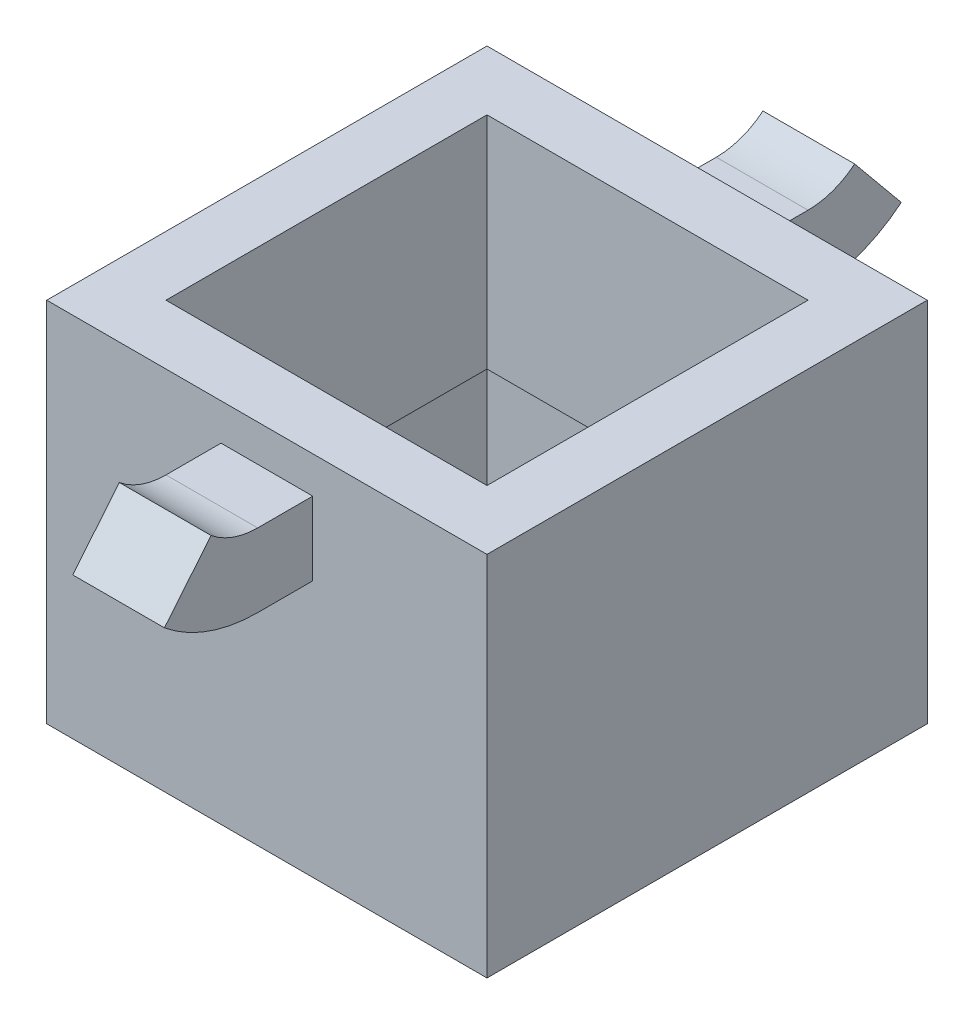
from build123d import *

# Parameters (mm, degrees)
SKETCH1_W           = 24
SKETCH1_H           = 24
BOSS_EXTRUDE1_DEPTH = 20
SKETCH5_W           = 5
SKETCH5_H           = 4
SKETCH3_W           = 20
SKETCH3_H           = 20
CUT_EXTRUDE5_DEPTH  = 6
SKETCH14_W          = 20
SKETCH14_H          = 20
CUT_EXTRUDE6_DEPTH  = 2
CUT_EXTRUDE7_REACH  = 14
SKETCH15_W          = 17.5
SKETCH15_H          = 17.5


with BuildPart() as part:
    # Sketch1 → Boss-Extrude1 (new body)
    with BuildSketch(Plane(origin=(0, 0, 0), x_dir=(1, 0, 0), z_dir=(0, 1, 0))):
        Rectangle(SKETCH1_W, SKETCH1_H)
    extrude(amount=BOSS_EXTRUDE1_DEPTH)

    # Sweep1: sweep along a path in Sketch6
    with BuildLine(Plane(origin=(0, 0, 0), x_dir=(0, 0, -1), z_dir=(1, 0, 0))) as sweep1_path:
        Line((12, 16), (15, 16))
        ThreePointArc((15, 16), (17.025627927, 16.352272006), (18.813398517, 17.367722833))
    # Sketch5 → Sweep1 (sweep)
    with BuildSketch(Plane(origin=(0, 0, -12), x_dir=(-1, 0, 0), z_dir=(0, 0, -1))):
        with Locations((0, 16)):
            Rectangle(SKETCH5_W, SKETCH5_H)
    sweep1 = sweep(path=sweep1_path.line)

    # Mirror1: Sweep1 across plane
    add(sweep1.mirror(Plane.XY))

    # Sketch3 → Cut-Extrude5 (cut)
    with BuildSketch(Plane.XZ):
        Rectangle(SKETCH3_W, SKETCH3_H)
    extrude(amount=-CUT_EXTRUDE5_DEPTH, mode=Mode.SUBTRACT)

    # Sketch14 → Cut-Extrude6 (cut)
    with BuildSketch(Plane.XZ.offset(-6)):
        Rectangle(SKETCH14_W, SKETCH14_H)
    extrude(amount=-CUT_EXTRUDE6_DEPTH, mode=Mode.SUBTRACT)

    # Sketch15 → Cut-Extrude7 (cut, up to next)
    with BuildSketch(Plane.XZ.offset(-8), mode=Mode.PRIVATE) as cut_extrude7_sk1:
        Rectangle(SKETCH15_W, SKETCH15_H)
    cut_extrude7_tool1 = extrude(cut_extrude7_sk1.sketch, amount=-CUT_EXTRUDE7_REACH, mode=Mode.PRIVATE) & part.part
    add(cut_extrude7_tool1.solids().sort_by_distance((0, 8, 0))[0], mode=Mode.SUBTRACT)


solid = part.part
